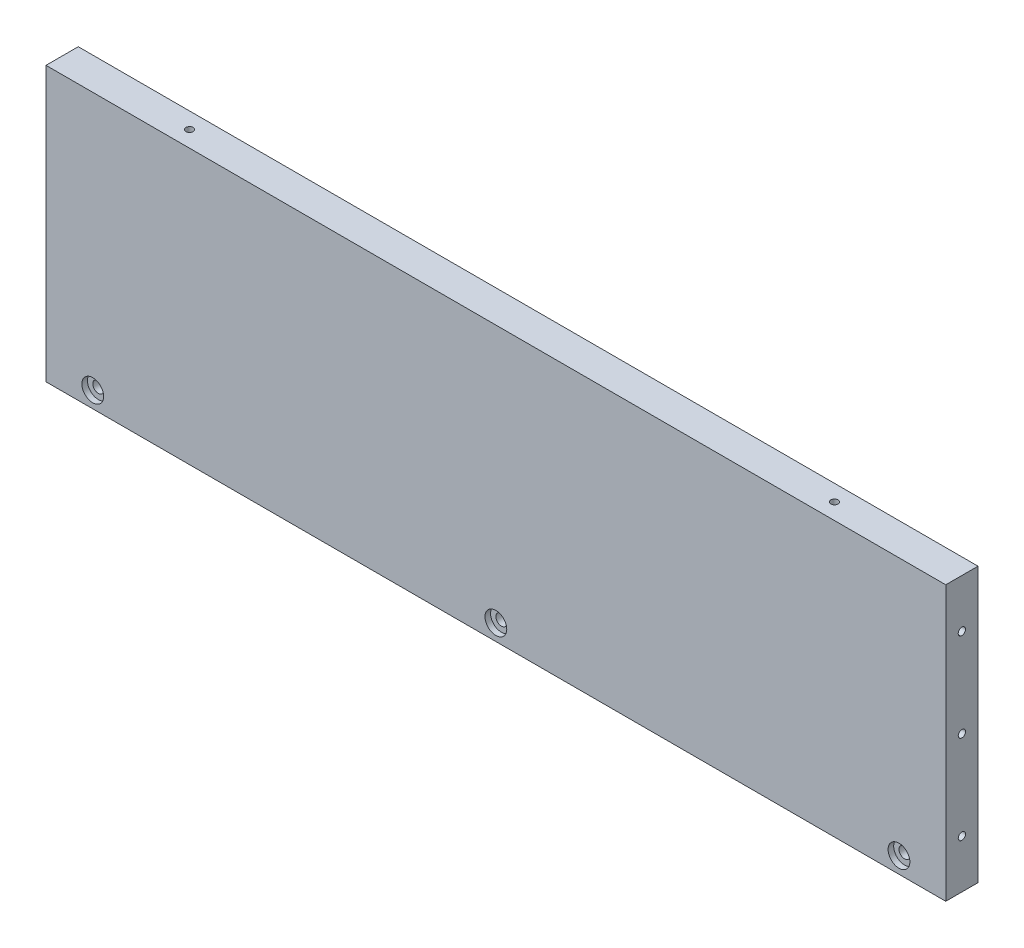
from build123d import *

# Parameters (mm, degrees)
SKETCH1_W                                           = 279
SKETCH1_H                                           = 85
BOSS_EXTRUDE1_DEPTH                                 = 10
CBORE_FOR_4_BINDING_HEAD_MACHINE_SCREW1_D           = 3.4544
CBORE_FOR_4_BINDING_HEAD_MACHINE_SCREW1_CBORE_D     = 6.74624
CBORE_FOR_4_BINDING_HEAD_MACHINE_SCREW1_CBORE_DEPTH = 1.7272
F_4_40_TAPPED_HOLE1_D                               = 2.2606
F_4_40_TAPPED_HOLE1_DEPTH                           = 7.6
F_4_40_TAPPED_HOLE1_TIP                             = 0.679152758
F_4_40_TAPPED_HOLE2_D                               = 2.2606
F_4_40_TAPPED_HOLE2_DEPTH                           = 7.6
F_4_40_TAPPED_HOLE2_TIP                             = 0.679152758
F_4_40_TAPPED_HOLE3_D                               = 2.2606
F_4_40_TAPPED_HOLE3_DEPTH                           = 7.6
F_4_40_TAPPED_HOLE3_TIP                             = 0.679152758


with BuildPart() as part:
    # Sketch1 → Boss-Extrude1 (new body)
    with BuildSketch(Plane.XY):
        with Locations((8.503783102, 35.532786885)):
            Rectangle(SKETCH1_W, SKETCH1_H)
    extrude(amount=BOSS_EXTRUDE1_DEPTH)

    # CBORE for #4 Binding Head Machine Screw1 (through all)
    with Locations(Plane.XY.offset(10)):
        with Locations((-116.496216898, -1.967213115), (8.503783102, -1.967213115), (133.503783102, -1.967213115)):
            CounterBoreHole(CBORE_FOR_4_BINDING_HEAD_MACHINE_SCREW1_D / 2, CBORE_FOR_4_BINDING_HEAD_MACHINE_SCREW1_CBORE_D / 2, CBORE_FOR_4_BINDING_HEAD_MACHINE_SCREW1_CBORE_DEPTH)

    # #4-40 Tapped Hole1
    with Locations(Plane.ZY.offset(130.996216898)):
        with Locations((5, 63.032786885), (5, 35.532786885), (5, 8.032786885)):
            Hole(F_4_40_TAPPED_HOLE1_D / 2, depth=F_4_40_TAPPED_HOLE1_DEPTH)
            with Locations((0, 0, -(F_4_40_TAPPED_HOLE1_DEPTH + F_4_40_TAPPED_HOLE1_TIP / 2))):  # 118° drill point
                Cone(0, F_4_40_TAPPED_HOLE1_D / 2, F_4_40_TAPPED_HOLE1_TIP, mode=Mode.SUBTRACT)

    # #4-40 Tapped Hole2
    with Locations(Plane(origin=(148.003783102, 0, 0), x_dir=(0, 0, -1), z_dir=(1, 0, 0))):
        with Locations((-5, 63.032786885), (-5, 35.532786885), (-5, 8.032786885)):
            Hole(F_4_40_TAPPED_HOLE2_D / 2, depth=F_4_40_TAPPED_HOLE2_DEPTH)
            with Locations((0, 0, -(F_4_40_TAPPED_HOLE2_DEPTH + F_4_40_TAPPED_HOLE2_TIP / 2))):  # 118° drill point
                Cone(0, F_4_40_TAPPED_HOLE2_D / 2, F_4_40_TAPPED_HOLE2_TIP, mode=Mode.SUBTRACT)

    # #4-40 Tapped Hole3
    with Locations(Plane(origin=(0, 78.032786885, 0), x_dir=(1, 0, 0), z_dir=(0, 1, 0))):
        with Locations((-91.496216898, -5), (108.503783102, -5)):
            Hole(F_4_40_TAPPED_HOLE3_D / 2, depth=F_4_40_TAPPED_HOLE3_DEPTH)
            with Locations((0, 0, -(F_4_40_TAPPED_HOLE3_DEPTH + F_4_40_TAPPED_HOLE3_TIP / 2))):  # 118° drill point
                Cone(0, F_4_40_TAPPED_HOLE3_D / 2, F_4_40_TAPPED_HOLE3_TIP, mode=Mode.SUBTRACT)


solid = part.part
